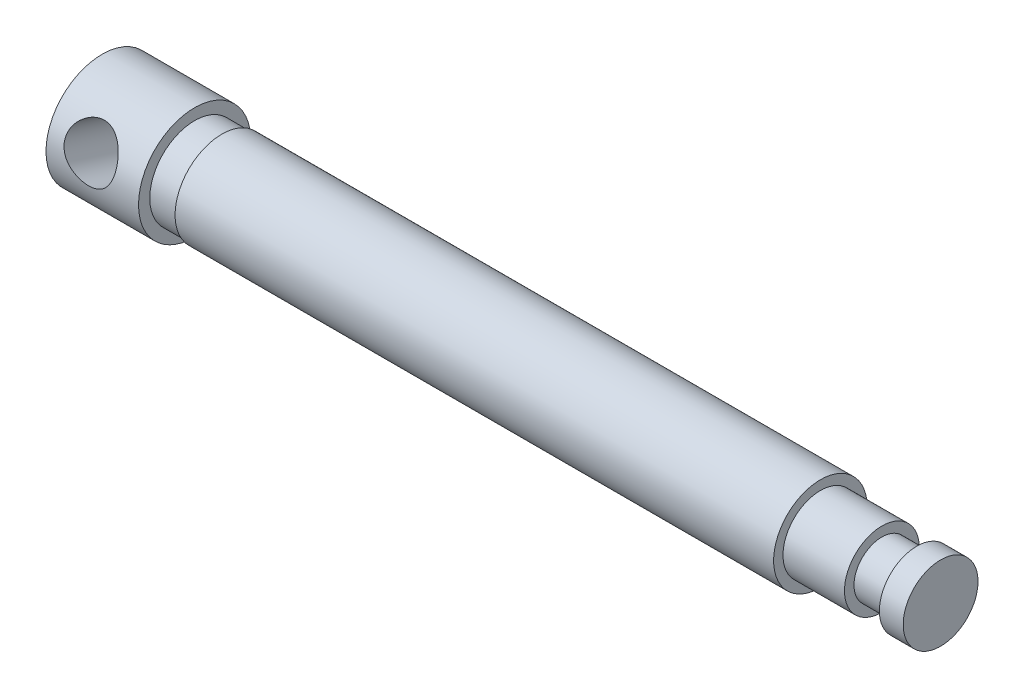
from build123d import *

# Parameters (mm, degrees)
SKETCH4_R                        = 7.9375
EXTRUDE1_DEPTH                   = 101.6
F_11_32_0_34375_DIAMETER_HOLE1_D = 8.73252


with BuildPart() as part:
    # Sketch1 → Revolve1 (revolve)
    with BuildSketch(Plane.XY):
        Polygon((0, 0), (20.32, 0), (20.32, -7.62), (15.706148476, -7.62), (15.706148476, -9.525), (0, -9.525), align=None)
    revolve(axis=Axis((158.75, 0, 0), (1, 0, 0)))

    # Sketch4 → Extrude1 (add)
    with BuildSketch(Plane(origin=(20.32, 0, 0), x_dir=(0, 0, -1), z_dir=(1, 0, 0))):
        Circle(SKETCH4_R)
    extrude(amount=EXTRUDE1_DEPTH)

    # Sketch5 → Revolve2 (revolve)
    with BuildSketch(Plane.XY):
        Polygon((121.92, 6.35), (132.354619201, 6.35), (132.354619201, 4.733622738), (138.281335828, 4.733622738), (138.281335828, 6.35), (142.322278983, 6.35), (142.322278983, 0), (121.92, 0), align=None)
    revolve(axis=Axis((142.322278983, 0, 0), (-1, 0, 0)))

    # 11/32 (0.34375) Diameter Hole1 (through all)
    with Locations(Plane(origin=(7.108304199, 2.913032452, 9.068619902), x_dir=(0, 0.952086079, -0.305830179), z_dir=(0, 0.305830179, 0.952086079))):
        with Locations((0, 0)):
            Hole(F_11_32_0_34375_DIAMETER_HOLE1_D / 2)


solid = part.part
